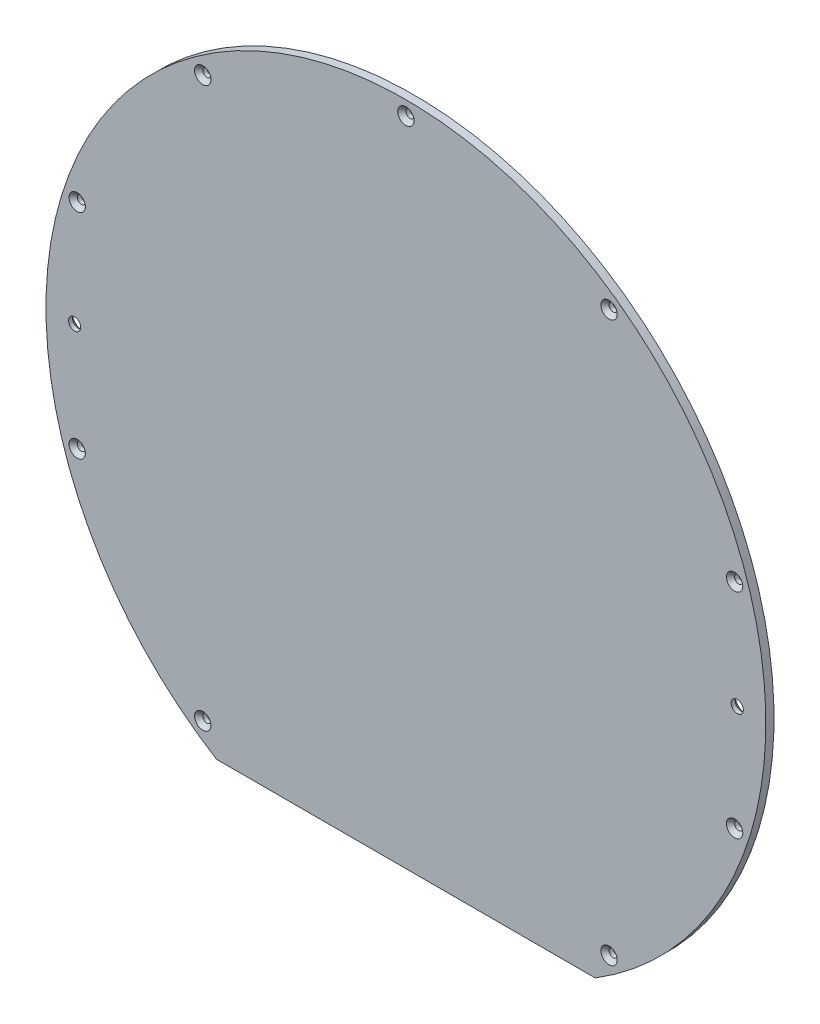
from build123d import *

# Parameters (mm, degrees)
RESSALTO_EXTRUS_O1_DEPTH = 2
CORTE_EXTRUS_O2_REACH    = 4
ESBO_O3_R                = 1.5
CHANFRO2_SIZE            = 1
CORTE_EXTRUS_O3_REACH    = 4
ESBO_O4_R                = 1
CHANFRO3_SIZE            = 1


with BuildPart() as part:
    # Esboço1 → Ressalto-extrusão1 (new body)
    with BuildSketch(Plane.XY):
        with BuildLine():
            Line((-46.303347611, -74.833147735), (46.303347611, -74.833147735))
            ThreePointArc((46.303347611, -74.833147735), (0, 88), (-46.303347611, -74.833147735))
        make_face()
    extrude(amount=RESSALTO_EXTRUS_O1_DEPTH)

    # Esboço3 → Corte-extrusão2 (cut, up to next)
    with BuildSketch(Plane.XY.offset(2), mode=Mode.PRIVATE) as corte_extrus_o2_sk1:
        with Locations((81, 0)):
            Circle(ESBO_O3_R)
    corte_extrus_o2_tool1 = extrude(corte_extrus_o2_sk1.sketch, amount=-CORTE_EXTRUS_O2_REACH, mode=Mode.PRIVATE) & part.part
    add(corte_extrus_o2_tool1.solids().sort_by_distance((81, 0, 2))[0], mode=Mode.SUBTRACT)
    # Esboço3 → Corte-extrusão2 (cut, up to next)
    with BuildSketch(Plane.XY.offset(2), mode=Mode.PRIVATE) as corte_extrus_o2_sk2:
        with Locations((-81, 0)):
            Circle(ESBO_O3_R)
    corte_extrus_o2_tool2 = extrude(corte_extrus_o2_sk2.sketch, amount=-CORTE_EXTRUS_O2_REACH, mode=Mode.PRIVATE) & part.part
    add(corte_extrus_o2_tool2.solids().sort_by_distance((-81, 0, 2))[0], mode=Mode.SUBTRACT)

    # Chanfro2
    chanfro2_edges = [part.edges().sort_by_distance(p)[0] for p in [
        (79.5, 0, 0),
        (-82.5, 0, 0),
    ]]
    chamfer(chanfro2_edges, length=CHANFRO2_SIZE)

    # Esboço4 → Corte-extrusão3 (cut, up to next)
    with BuildSketch(Plane.XY.offset(2), mode=Mode.PRIVATE) as corte_extrus_o3_sk1:
        with Locations((-49.667853819, -68.361936025)):
            Circle(ESBO_O4_R)
    corte_extrus_o3_tool1 = extrude(corte_extrus_o3_sk1.sketch, amount=-CORTE_EXTRUS_O3_REACH, mode=Mode.PRIVATE) & part.part
    add(corte_extrus_o3_tool1.solids().sort_by_distance((-49.667854, -68.361936, 2))[0], mode=Mode.SUBTRACT)
    # Esboço4 → Corte-extrusão3 (cut, up to next)
    with BuildSketch(Plane.XY.offset(2), mode=Mode.PRIVATE) as corte_extrus_o3_sk2:
        with Locations((-80.364275627, -26.111936025)):
            Circle(ESBO_O4_R)
    corte_extrus_o3_tool2 = extrude(corte_extrus_o3_sk2.sketch, amount=-CORTE_EXTRUS_O3_REACH, mode=Mode.PRIVATE) & part.part
    add(corte_extrus_o3_tool2.solids().sort_by_distance((-80.364276, -26.111936, 2))[0], mode=Mode.SUBTRACT)
    # Esboço4 → Corte-extrusão3 (cut, up to next)
    with BuildSketch(Plane.XY.offset(2), mode=Mode.PRIVATE) as corte_extrus_o3_sk3:
        with Locations((-80.364275627, 26.111936025)):
            Circle(ESBO_O4_R)
    corte_extrus_o3_tool3 = extrude(corte_extrus_o3_sk3.sketch, amount=-CORTE_EXTRUS_O3_REACH, mode=Mode.PRIVATE) & part.part
    add(corte_extrus_o3_tool3.solids().sort_by_distance((-80.364276, 26.111936, 2))[0], mode=Mode.SUBTRACT)
    # Esboço4 → Corte-extrusão3 (cut, up to next)
    with BuildSketch(Plane.XY.offset(2), mode=Mode.PRIVATE) as corte_extrus_o3_sk4:
        with Locations((-49.667853819, 68.361936025)):
            Circle(ESBO_O4_R)
    corte_extrus_o3_tool4 = extrude(corte_extrus_o3_sk4.sketch, amount=-CORTE_EXTRUS_O3_REACH, mode=Mode.PRIVATE) & part.part
    add(corte_extrus_o3_tool4.solids().sort_by_distance((-49.667854, 68.361936, 2))[0], mode=Mode.SUBTRACT)
    # Esboço4 → Corte-extrusão3 (cut, up to next)
    with BuildSketch(Plane.XY.offset(2), mode=Mode.PRIVATE) as corte_extrus_o3_sk5:
        with Locations((0, 84.5)):
            Circle(ESBO_O4_R)
    corte_extrus_o3_tool5 = extrude(corte_extrus_o3_sk5.sketch, amount=-CORTE_EXTRUS_O3_REACH, mode=Mode.PRIVATE) & part.part
    add(corte_extrus_o3_tool5.solids().sort_by_distance((0, 84.5, 2))[0], mode=Mode.SUBTRACT)
    # Esboço4 → Corte-extrusão3 (cut, up to next)
    with BuildSketch(Plane.XY.offset(2), mode=Mode.PRIVATE) as corte_extrus_o3_sk6:
        with Locations((49.667853819, 68.361936025)):
            Circle(ESBO_O4_R)
    corte_extrus_o3_tool6 = extrude(corte_extrus_o3_sk6.sketch, amount=-CORTE_EXTRUS_O3_REACH, mode=Mode.PRIVATE) & part.part
    add(corte_extrus_o3_tool6.solids().sort_by_distance((49.667854, 68.361936, 2))[0], mode=Mode.SUBTRACT)
    # Esboço4 → Corte-extrusão3 (cut, up to next)
    with BuildSketch(Plane.XY.offset(2), mode=Mode.PRIVATE) as corte_extrus_o3_sk7:
        with Locations((80.364275627, 26.111936025)):
            Circle(ESBO_O4_R)
    corte_extrus_o3_tool7 = extrude(corte_extrus_o3_sk7.sketch, amount=-CORTE_EXTRUS_O3_REACH, mode=Mode.PRIVATE) & part.part
    add(corte_extrus_o3_tool7.solids().sort_by_distance((80.364276, 26.111936, 2))[0], mode=Mode.SUBTRACT)
    # Esboço4 → Corte-extrusão3 (cut, up to next)
    with BuildSketch(Plane.XY.offset(2), mode=Mode.PRIVATE) as corte_extrus_o3_sk8:
        with Locations((80.364275627, -26.111936025)):
            Circle(ESBO_O4_R)
    corte_extrus_o3_tool8 = extrude(corte_extrus_o3_sk8.sketch, amount=-CORTE_EXTRUS_O3_REACH, mode=Mode.PRIVATE) & part.part
    add(corte_extrus_o3_tool8.solids().sort_by_distance((80.364276, -26.111936, 2))[0], mode=Mode.SUBTRACT)
    # Esboço4 → Corte-extrusão3 (cut, up to next)
    with BuildSketch(Plane.XY.offset(2), mode=Mode.PRIVATE) as corte_extrus_o3_sk9:
        with Locations((49.667853819, -68.361936025)):
            Circle(ESBO_O4_R)
    corte_extrus_o3_tool9 = extrude(corte_extrus_o3_sk9.sketch, amount=-CORTE_EXTRUS_O3_REACH, mode=Mode.PRIVATE) & part.part
    add(corte_extrus_o3_tool9.solids().sort_by_distance((49.667854, -68.361936, 2))[0], mode=Mode.SUBTRACT)

    # Chanfro3
    chanfro3_edges = [part.edges().sort_by_distance(p)[0] for p in [
        (-50.667853819, -68.361936025, 2),
        (-81.364275627, -26.111936025, 2),
        (-81.364275627, 26.111936025, 2),
        (-50.667853819, 68.361936025, 2),
        (-1, 84.5, 2),
        (48.667853819, 68.361936025, 2),
        (79.364275627, 26.111936025, 2),
        (79.364275627, -26.111936025, 2),
        (48.667853819, -68.361936025, 2),
    ]]
    chamfer(chanfro3_edges, length=CHANFRO3_SIZE)


solid = part.part
